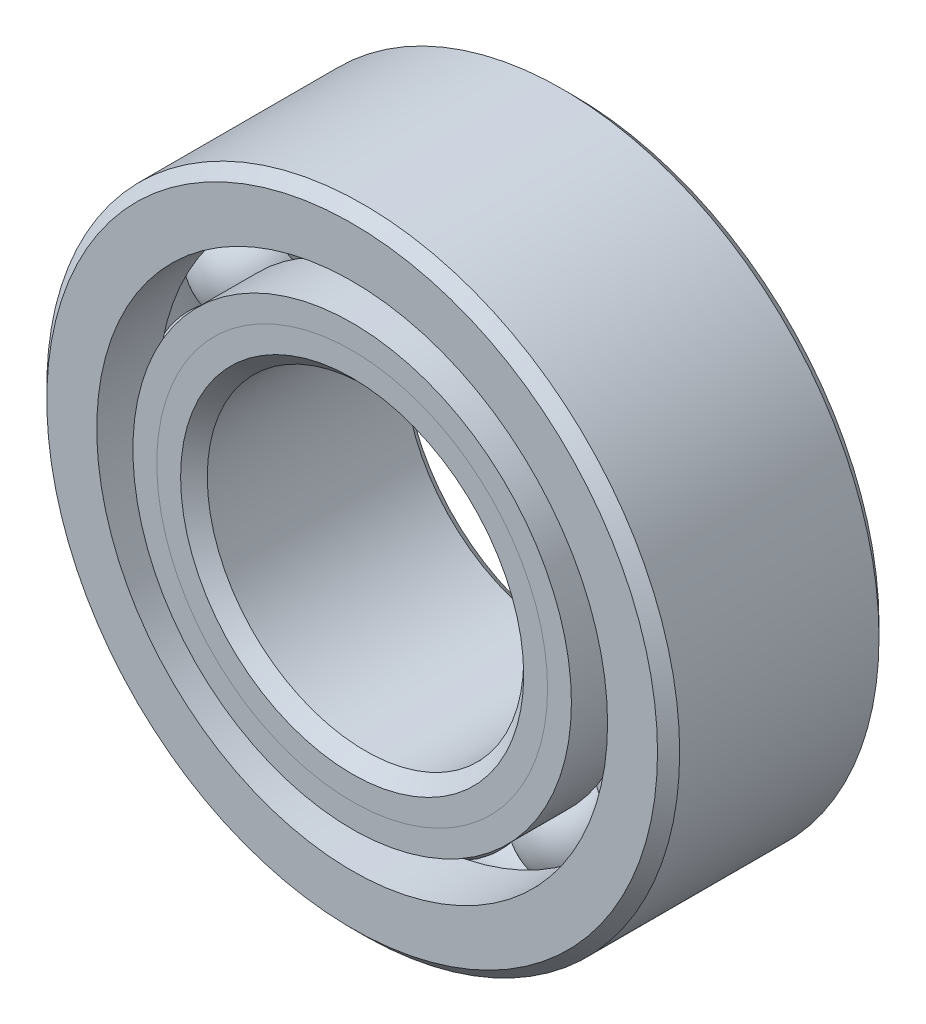
from build123d import *

# Parameters (mm, degrees)
CIRPATTERN1_COUNT = 12


with BuildPart() as part:
    # Sketch1 → Revolve1 (revolve)
    with BuildSketch(Plane(origin=(0, 0, 0), x_dir=(0, 0, -1), z_dir=(1, 0, 0))):
        with BuildLine():
            Line((1.25015625, 3.96875), (-1.25015625, 3.96875))
            Line((-1.25015625, 3.96875), (-1.3890625, 3.82984375))
            Line((-1.3890625, 3.82984375), (-1.3890625, 3.203348214))
            Line((-1.3890625, 3.203348214), (-0.617361111, 3.203348214))
            ThreePointArc((-0.617361111, 3.203348214), (0, 3.63426038), (0.617361111, 3.203348214))
            Line((0.617361111, 3.203348214), (1.3890625, 3.203348214))
            Line((1.3890625, 3.203348214), (1.3890625, 3.82984375))
            Line((1.3890625, 3.82984375), (1.25015625, 3.96875))
        make_face()
    revolve(axis=Axis((0, 0, 1.3890625), (0, 0, -1)))


with BuildPart() as body_2:
    # Sketch2 → Revolve2 (revolve)
    with BuildSketch(Plane(origin=(0, 0, 0), x_dir=(0, 0, -1), z_dir=(1, 0, 0))):
        with BuildLine():
            Line((-1.3890625, 2.749776786), (-0.617361111, 2.749776786))
            ThreePointArc((-0.617361111, 2.749776786), (-0.376437258, 2.437246737), (0, 2.31886462))
            Line((0, 2.31886462), (0, 2.15161981))
            Line((0, 2.15161981), (-1.089984012, 2.15161981))
            Line((-1.089984012, 2.15161981), (-1.3890625, 2.450698298))
            Line((-1.3890625, 2.450698298), (-1.3890625, 2.749776786))
        make_face()
    revolve(axis=Axis((0, 0, 1.3890625), (0, 0, -1)))


with BuildPart() as body_3:
    # Sketch3 → Revolve3 (revolve)
    with BuildSketch(Plane(origin=(0, 0, 0), x_dir=(0, 0, -1), z_dir=(1, 0, 0))):
        with BuildLine():
            Line((-1.3890625, 2.450698298), (-1.089984012, 2.15161981))
            Line((-1.089984012, 2.15161981), (0, 2.15161981))
            Line((0, 2.15161981), (0, 2.31886462))
            ThreePointArc((0, 2.31886462), (0.376437258, 2.437246737), (0.617361111, 2.749776786))
            Line((0.617361111, 2.749776786), (1.3890625, 2.749776786))
            Line((1.3890625, 2.749776786), (1.3890625, 2.12328125))
            Line((1.3890625, 2.12328125), (1.25015625, 1.984375))
            Line((1.25015625, 1.984375), (-1.22181769, 1.984375))
            Line((-1.22181769, 1.984375), (-1.3890625, 2.15161981))
            Line((-1.3890625, 2.15161981), (-1.3890625, 2.450698298))
        make_face()
    revolve(axis=Axis((0, 0, 1.3890625), (0, 0, -1)))


with BuildPart() as body_4:
    # Sketch4 → Revolve4 (revolve)
    with BuildSketch(Plane(origin=(0, 0, 0), x_dir=(0, 0, -1), z_dir=(1, 0, 0))):
        with BuildLine():
            Line((-0.65769788, 2.9765625), (0.65769788, 2.9765625))
            ThreePointArc((0.65769788, 2.9765625), (0, 3.63426038), (-0.65769788, 2.9765625))
        make_face()
    revolve(axis=Axis((0, 2.9765625, 0.65769788), (0, 0, -1)))


with BuildPart() as cirpattern1_1:
    # CirPattern1: pattern copy
    add(body_4.part.rotate(Axis((0, 0, -1.3890625), (0, 0, 1)), 1 * 360 / CIRPATTERN1_COUNT))


with BuildPart() as cirpattern1_2:
    # CirPattern1: pattern copy
    add(body_4.part.rotate(Axis((0, 0, -1.3890625), (0, 0, 1)), 2 * 360 / CIRPATTERN1_COUNT))


with BuildPart() as cirpattern1_3:
    # CirPattern1: pattern copy
    add(body_4.part.rotate(Axis((0, 0, -1.3890625), (0, 0, 1)), 3 * 360 / CIRPATTERN1_COUNT))


with BuildPart() as cirpattern1_4:
    # CirPattern1: pattern copy
    add(body_4.part.rotate(Axis((0, 0, -1.3890625), (0, 0, 1)), 4 * 360 / CIRPATTERN1_COUNT))


with BuildPart() as cirpattern1_5:
    # CirPattern1: pattern copy
    add(body_4.part.rotate(Axis((0, 0, -1.3890625), (0, 0, 1)), 5 * 360 / CIRPATTERN1_COUNT))


with BuildPart() as cirpattern1_6:
    # CirPattern1: pattern copy
    add(body_4.part.rotate(Axis((0, 0, -1.3890625), (0, 0, 1)), 6 * 360 / CIRPATTERN1_COUNT))


with BuildPart() as cirpattern1_7:
    # CirPattern1: pattern copy
    add(body_4.part.rotate(Axis((0, 0, -1.3890625), (0, 0, 1)), 7 * 360 / CIRPATTERN1_COUNT))


with BuildPart() as cirpattern1_8:
    # CirPattern1: pattern copy
    add(body_4.part.rotate(Axis((0, 0, -1.3890625), (0, 0, 1)), 8 * 360 / CIRPATTERN1_COUNT))


with BuildPart() as cirpattern1_9:
    # CirPattern1: pattern copy
    add(body_4.part.rotate(Axis((0, 0, -1.3890625), (0, 0, 1)), 9 * 360 / CIRPATTERN1_COUNT))


with BuildPart() as cirpattern1_10:
    # CirPattern1: pattern copy
    add(body_4.part.rotate(Axis((0, 0, -1.3890625), (0, 0, 1)), 10 * 360 / CIRPATTERN1_COUNT))


with BuildPart() as cirpattern1_11:
    # CirPattern1: pattern copy
    add(body_4.part.rotate(Axis((0, 0, -1.3890625), (0, 0, 1)), 11 * 360 / CIRPATTERN1_COUNT))


solid = Compound([part.part, body_2.part, body_3.part, body_4.part, cirpattern1_1.part, cirpattern1_2.part, cirpattern1_3.part, cirpattern1_4.part, cirpattern1_5.part, cirpattern1_6.part, cirpattern1_7.part, cirpattern1_8.part, cirpattern1_9.part, cirpattern1_10.part, cirpattern1_11.part])
